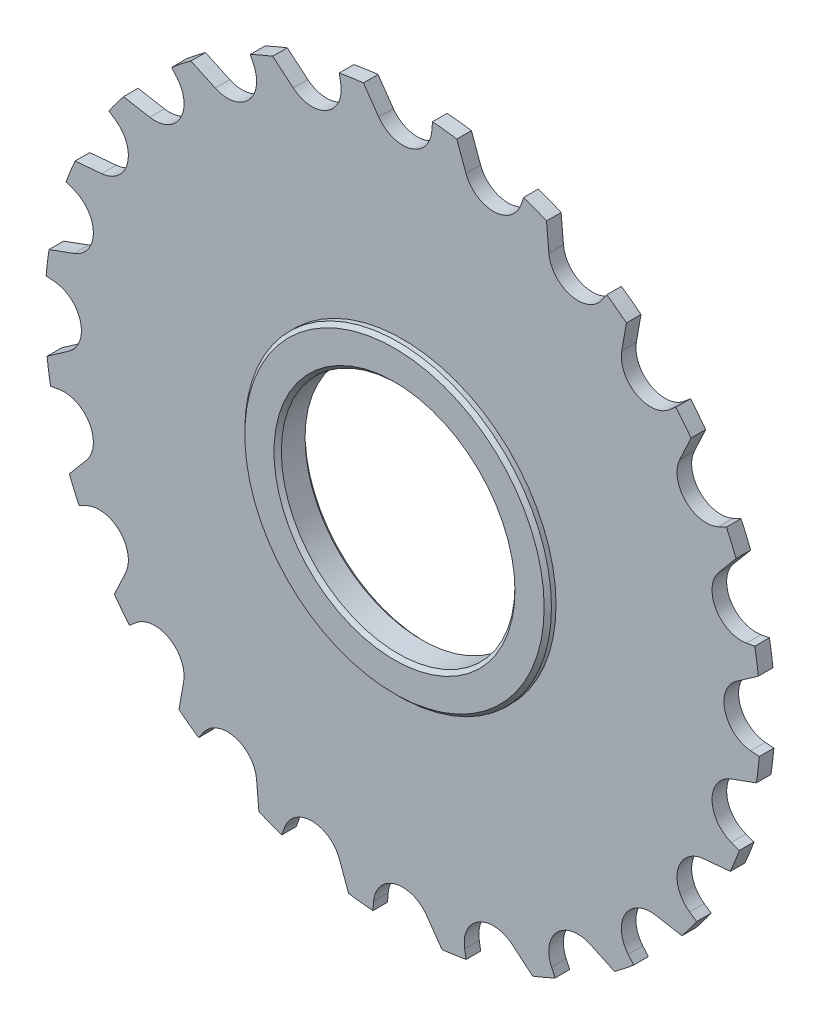
from build123d import *

# Parameters (mm, degrees)
ESQUISSE1_R                  = 49
EXTRUSION1_DEPTH             = 1
ENL_V_MAT_EXTRU_1_DEPTH      = 2
R_P_TITION_CIRCULAIRE1_COUNT = 24
ESQUISSE3_R                  = 21
EXTRUSION2_DEPTH             = 2.125
ESQUISSE4_R                  = 16
ENL_V_MAT_EXTRU_2_DEPTH      = 3.125
ENL_V_MAT_EXTRU_2_DEPTH_BACK = 3.125
CHANFREIN1_SIZE              = 0.5


with BuildPart() as part:
    # Esquisse1 → Extrusion1 (new body, symmetric)
    with BuildSketch(Plane.XY):
        Circle(ESQUISSE1_R)
    extrude(amount=EXTRUSION1_DEPTH, both=True)

    # Esquisse2 → Enlèv. mat.-Extru.1 (cut, symmetric)
    with BuildSketch(Plane.XY):
        with BuildLine():
            Line((-5.376168106, 48.704176582), (-3.276608177, 45.705694255))
            ThreePointArc((-3.276608177, 45.705694255), (1.042685581, 44.138289656), (3.986086914, 47.666666667))
            Line((3.986086914, 47.666666667), (4.083333333, 48.829564701))
            ThreePointArc((4.083333333, 48.829564701), (-0.649450523, 48.995695872), (-5.376168106, 48.704176582))
        make_face()
    enl_v_mat_extru_1 = extrude(amount=ENL_V_MAT_EXTRU_1_DEPTH, both=True, mode=Mode.SUBTRACT)

    # Répétition circulaire1: Enlèv. mat.-Extru.1 ×24 about axis
    r_p_tition_circulaire1_axis = Axis((0, 0, 0), (0, 0, 1))
    for i in range(1, R_P_TITION_CIRCULAIRE1_COUNT):
        add(enl_v_mat_extru_1.rotate(r_p_tition_circulaire1_axis, i * 360 / R_P_TITION_CIRCULAIRE1_COUNT), mode=Mode.SUBTRACT)

    # Esquisse3 → Extrusion2 (add, symmetric)
    with BuildSketch(Plane.XY):
        Circle(ESQUISSE3_R)
    extrude(amount=EXTRUSION2_DEPTH, both=True)

    # Esquisse4 → Enlèv. mat.-Extru.2 (cut, two sides)
    with BuildSketch(Plane.XY) as enl_v_mat_extru_2_sk:
        Circle(ESQUISSE4_R)
    extrude(amount=ENL_V_MAT_EXTRU_2_DEPTH, mode=Mode.SUBTRACT)
    extrude(enl_v_mat_extru_2_sk.sketch, amount=-ENL_V_MAT_EXTRU_2_DEPTH_BACK, mode=Mode.SUBTRACT)

    # Chanfrein1
    chanfrein1_edges = [part.edges().sort_by_distance(p)[0] for p in [
        (-21, 0, -2.125),
        (-21, 0, 2.125),
        (-16, 0, -2.125),
        (-16, 0, 2.125),
    ]]
    chamfer(chanfrein1_edges, length=CHANFREIN1_SIZE)


solid = part.part
